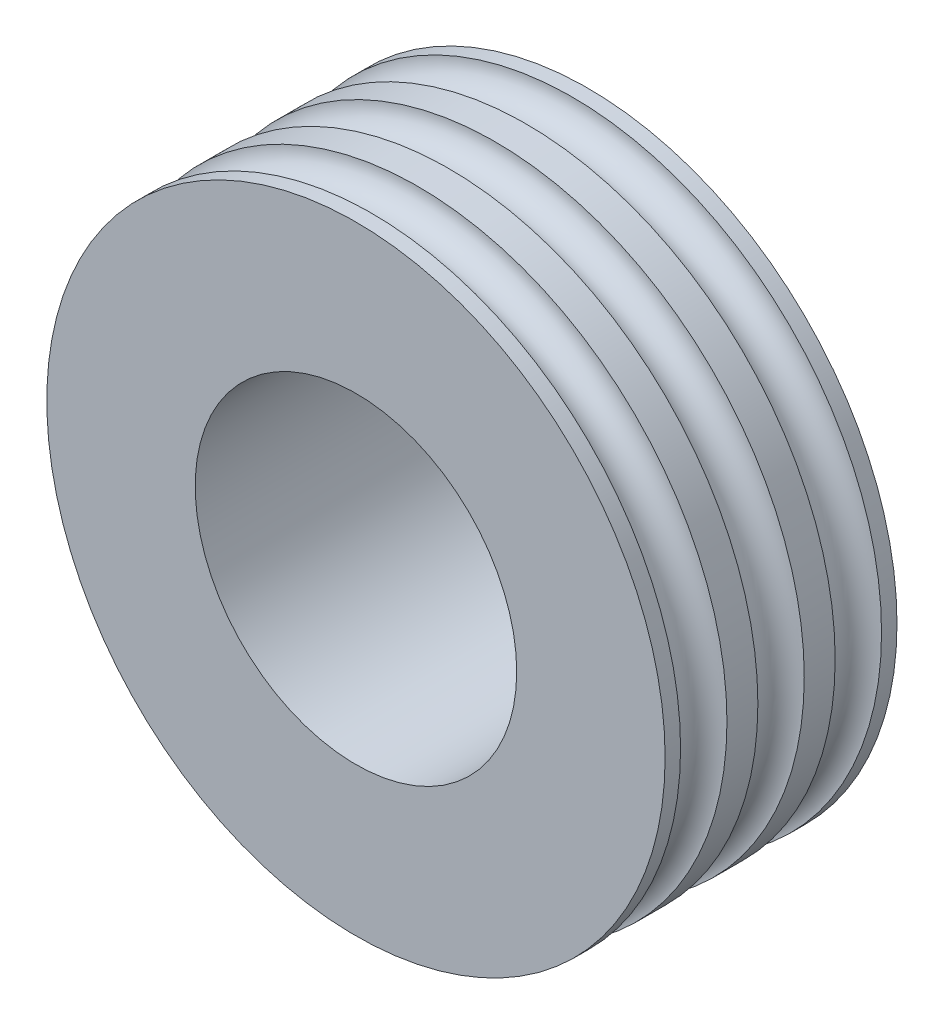
from build123d import *


with BuildPart() as part:
    # Sketch2 → Revolve1 (revolve)
    with BuildSketch(Plane(origin=(0, 0, 0), x_dir=(0, 0, -1), z_dir=(1, 0, 0))):
        with BuildLine():
            Line((0.25, 2.6), (0.25, 5))
            Line((0.25, 5), (0, 5))
            ThreePointArc((0, 5), (-0.375, 4.625), (-0.75, 5))
            Line((-0.75, 5), (-1, 5))
            Line((-1, 5), (-1, 2.6))
            Line((-1, 2.6), (0.25, 2.6))
        make_face()
    revolve1 = revolve(axis=Axis((0, 0, 3.014677367), (0, 0, -1)))

    # Mirror1: part across plane


with BuildPart() as part_1:
    add(part.part)
    add(part.part.mirror(Plane(origin=(0, 0, -0.25), x_dir=(1, 0, 0), z_dir=(0, 0, -1))))

    # Mirror2: Revolve1 across plane
    add(revolve1.mirror(Plane(origin=(0, 5, 1), x_dir=(1, 0, 0), z_dir=(0, 0, -1))))


solid = part_1.part
